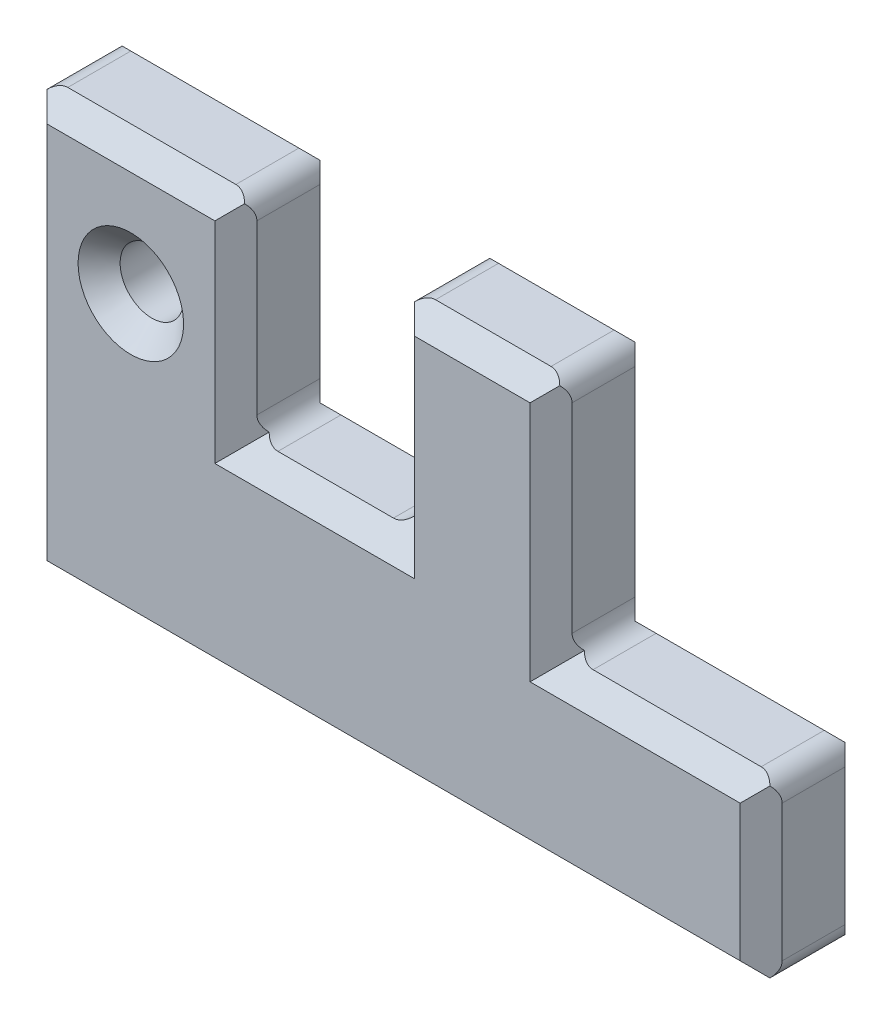
from build123d import *

# Parameters (mm, degrees)
BOSS_EXTRUDE1_DEPTH = 0.5
CHAMFER1_SIZE       = 0.1
FILLET4_R           = 0.1
SKETCH2_R           = 0.151033701
CUT_EXTRUDE1_DEPTH  = 1.5
CHAMFER2_SIZE       = 0.1


with BuildPart() as part:
    # Sketch1 → Boss-Extrude1 (new body)
    with BuildSketch(Plane.XY):
        Polygon((0, 0), (0, 2), (1, 2), (1, 1), (1.75, 1), (1.75, 2), (2.5, 2), (2.5, 0.85), (3.5, 0.85), (3.5, 0), align=None)
    extrude(amount=BOSS_EXTRUDE1_DEPTH)

    # Chamfer1
    chamfer1_edges = [part.edges().sort_by_distance(p)[0] for p in [
        (0, 1, 0),
        (0.5, 2, 0),
        (1, 1.5, 0),
        (1.375, 1, 0),
        (1.75, 1.5, 0),
        (2.125, 2, 0),
        (2.5, 1.425, 0),
        (3, 0.85, 0.5),
        (3, 0.85, 0),
        (3.5, 0.425, 0),
        (1.75, 0, 0),
        (2.5, 1.425, 0.5),
        (2.125, 2, 0.5),
        (1.75, 1.5, 0.5),
        (1.375, 1, 0.5),
        (1, 1.5, 0.5),
        (0.5, 2, 0.5),
        (0, 1, 0.5),
        (1.75, 0, 0.5),
        (3.5, 0.425, 0.5),
    ]]
    chamfer(chamfer1_edges, length=CHAMFER1_SIZE)

    # Fillet4
    fillet4_edges = [part.edges().sort_by_distance(p)[0] for p in [
        (3.5, 0.85, 0.25),
        (3.5, 0, 0.25),
        (2.5, 0.85, 0.25),
        (2.5, 2, 0.25),
        (1.75, 2, 0.25),
        (1.75, 1, 0.25),
        (1, 1, 0.25),
        (1, 2, 0.25),
        (0, 2, 0.25),
        (0, 0, 0.25),
    ]]
    fillet(fillet4_edges, radius=FILLET4_R)

    # Sketch2 → Cut-Extrude1 (cut, through all)
    with BuildSketch(Plane.XY.offset(0.5)):
        with Locations((0.5, 1.4)):
            Circle(SKETCH2_R)
    extrude(amount=-CUT_EXTRUDE1_DEPTH, mode=Mode.SUBTRACT)

    # Chamfer2
    chamfer2_edges = [part.edges().sort_by_distance(p)[0] for p in [
        (0.348966299, 1.4, 0.5),
    ]]
    chamfer(chamfer2_edges, length=CHAMFER2_SIZE)


solid = part.part
